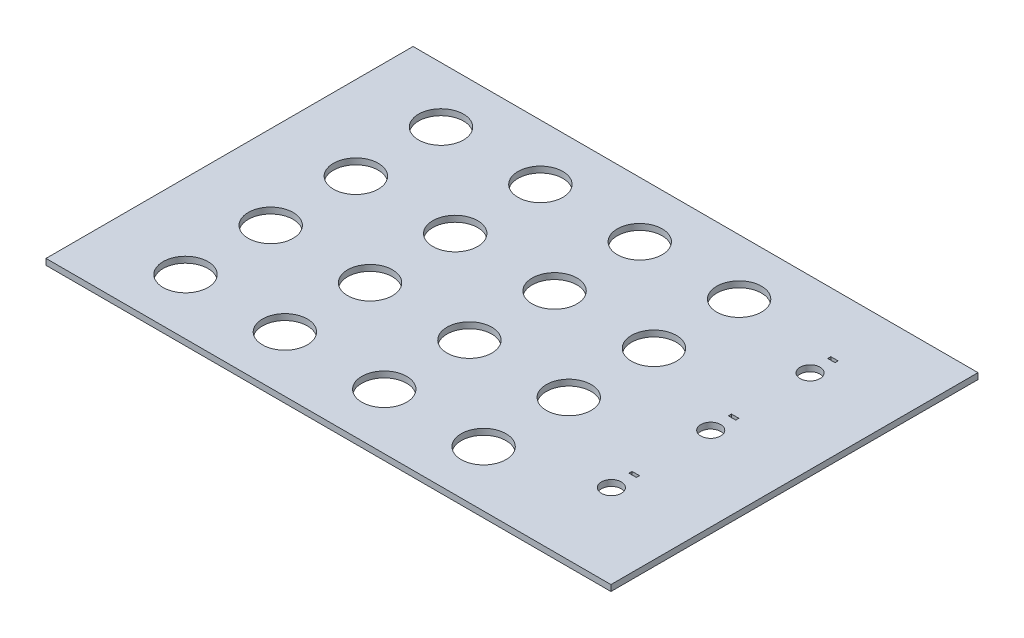
from build123d import *

# Parameters (mm, degrees)
SKETCH1_W           = 199
SKETCH1_H           = 129.3
SKETCH1_R           = 7.9
SKETCH1_R_2         = 3.5
SKETCH1_W_2         = 2.6
SKETCH1_H_2         = 1.1
BOSS_EXTRUDE1_DEPTH = 2.13


with BuildPart() as part:
    # Sketch1 → Boss-Extrude1 (new body)
    with BuildSketch(Plane(origin=(0, 0, 0), x_dir=(1, 0, 0), z_dir=(0, 1, 0))):
        Rectangle(SKETCH1_W, SKETCH1_H)
        with Locations((-70, 45)):
            Circle(SKETCH1_R, mode=Mode.SUBTRACT)
        with Locations((-35, 45)):
            Circle(SKETCH1_R, mode=Mode.SUBTRACT)
        with Locations((0, 45)):
            Circle(SKETCH1_R, mode=Mode.SUBTRACT)
        with Locations((35, 45)):
            Circle(SKETCH1_R, mode=Mode.SUBTRACT)
        with Locations((-35, 15)):
            Circle(SKETCH1_R, mode=Mode.SUBTRACT)
        with Locations((0, 15)):
            Circle(SKETCH1_R, mode=Mode.SUBTRACT)
        with Locations((35, 15)):
            Circle(SKETCH1_R, mode=Mode.SUBTRACT)
        with Locations((-35, -15)):
            Circle(SKETCH1_R, mode=Mode.SUBTRACT)
        with Locations((0, -15)):
            Circle(SKETCH1_R, mode=Mode.SUBTRACT)
        with Locations((35, -15)):
            Circle(SKETCH1_R, mode=Mode.SUBTRACT)
        with Locations((-35, -45)):
            Circle(SKETCH1_R, mode=Mode.SUBTRACT)
        with Locations((0, -45)):
            Circle(SKETCH1_R, mode=Mode.SUBTRACT)
        with Locations((35, -45)):
            Circle(SKETCH1_R, mode=Mode.SUBTRACT)
        with Locations((-70, 15)):
            Circle(SKETCH1_R, mode=Mode.SUBTRACT)
        with Locations((-70, -15)):
            Circle(SKETCH1_R, mode=Mode.SUBTRACT)
        with Locations((-70, -45)):
            Circle(SKETCH1_R, mode=Mode.SUBTRACT)
        with Locations((70, 35)):
            Circle(SKETCH1_R_2, mode=Mode.SUBTRACT)
        with Locations((70, 0)):
            Circle(SKETCH1_R_2, mode=Mode.SUBTRACT)
        with Locations((70, -35)):
            Circle(SKETCH1_R_2, mode=Mode.SUBTRACT)
        with Locations((70, 43.05)):
            Rectangle(SKETCH1_W_2, SKETCH1_H_2, mode=Mode.SUBTRACT)
        with Locations((70, 8.05)):
            Rectangle(SKETCH1_W_2, SKETCH1_H_2, mode=Mode.SUBTRACT)
        with Locations((70, -26.95)):
            Rectangle(SKETCH1_W_2, SKETCH1_H_2, mode=Mode.SUBTRACT)
    extrude(amount=BOSS_EXTRUDE1_DEPTH)


solid = part.part
